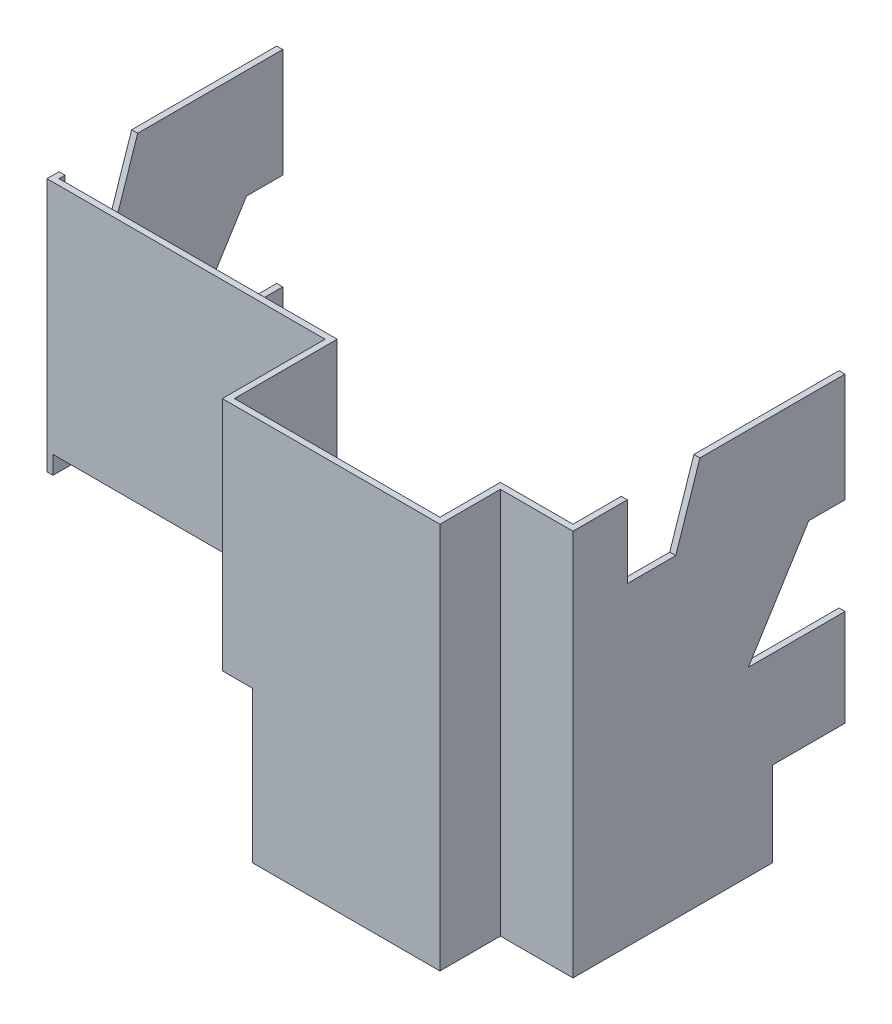
from build123d import *

# Parameters (mm, degrees)
BOSS_EXTRUDE1_DEPTH = 406.4
SKETCH2_W           = 317.5
SKETCH2_H           = 158.75
CUT_EXTRUDE1_DEPTH  = 114.3
CUT_EXTRUDE2_REACH  = 598.9
CUT_EXTRUDE3_REACH  = 598.9
SKETCH4_W           = 76.2
SKETCH4_H           = 88.9
CUT_EXTRUDE5_DEPTH  = 597.9


with BuildPart() as part:
    # Sketch1 → Boss-Extrude1 (new body)
    with BuildSketch(Plane(origin=(0, 0, 0), x_dir=(1, 0, 0), z_dir=(0, 1, 0))):
        Polygon((0, 0), (0, 241.3), (6.35, 241.3), (6.35, 6.35), (298.45, 6.35), (298.45, -101.6), (514.35, -101.6), (514.35, -38.1), (590.55, -38.1), (590.55, 241.3), (596.9, 241.3), (596.9, -44.45), (520.7, -44.45), (520.7, -107.95), (292.1, -107.95), (292.1, 0), align=None)
    extrude(amount=BOSS_EXTRUDE1_DEPTH)

    # Sketch2 → Cut-Extrude1 (cut)
    with BuildSketch(Plane.XY.offset(107.95)):
        with Locations((165.1, 79.375)):
            Rectangle(SKETCH2_W, SKETCH2_H)
    extrude(amount=-CUT_EXTRUDE1_DEPTH, mode=Mode.SUBTRACT)

    # Sketch3 → Cut-Extrude2 (cut, up to next)
    with BuildSketch(Plane.ZY, mode=Mode.PRIVATE) as cut_extrude2_sk1:
        Polygon((-76.2, 88.9), (-76.2, 139.7), (0, 139.7), (0, 0), (-241.3, 0), (-241.3, 88.9), align=None)
    cut_extrude2_tool1 = extrude(cut_extrude2_sk1.sketch, amount=-CUT_EXTRUDE2_REACH, mode=Mode.PRIVATE) & part.part
    add(cut_extrude2_tool1.solids().sort_by_distance((0, 55.127707, -108.030892))[0], mode=Mode.SUBTRACT)

    # Sketch4 → Cut-Extrude3 (cut, up to next)
    with BuildSketch(Plane(origin=(596.9, 0, 0), x_dir=(0, 0, -1), z_dir=(1, 0, 0)), mode=Mode.PRIVATE) as cut_extrude3_sk1:
        with Locations((203.2, 44.45)):
            Rectangle(SKETCH4_W, SKETCH4_H)
    cut_extrude3_tool1 = extrude(cut_extrude3_sk1.sketch, amount=-CUT_EXTRUDE3_REACH, mode=Mode.PRIVATE) & part.part
    add(cut_extrude3_tool1.solids().sort_by_distance((596.9, 44.45, -203.2))[0], mode=Mode.SUBTRACT)

    # Sketch6 → Cut-Extrude5 (cut, through all)
    with BuildSketch(Plane.ZY):
        Polygon((-241.3, 292.1), (-203.2, 292.1), (-139.7, 190.5), (-241.3, 190.5), align=None)
        Polygon((-88.9, 406.4), (-12.7, 406.4), (-12.7, 330.2), (-63.5, 330.2), align=None)
    extrude(amount=-CUT_EXTRUDE5_DEPTH, mode=Mode.SUBTRACT)


solid = part.part
